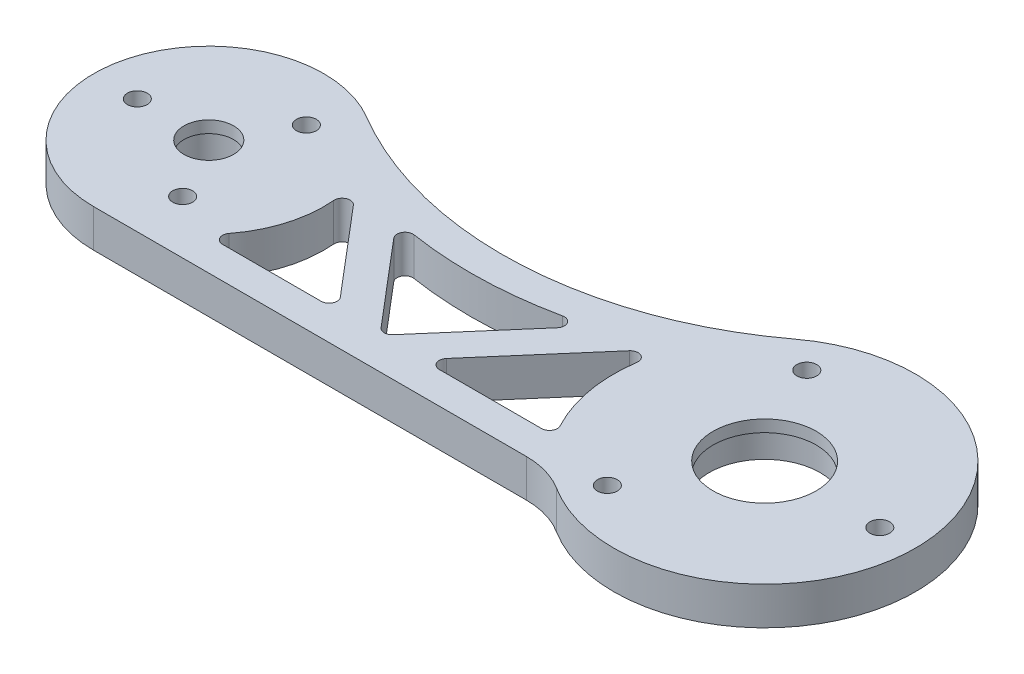
from build123d import *

# Parameters (mm, degrees)
BOSS_EXTRUDE1_DEPTH   = 4.7625
CUT_EXTRUDE1_DEPTH    = 5.7625
CUT_EXTRUDE2_DEPTH    = 5.7625
FILLET1_R             = 1
SKETCH4_R             = 4
BOSS_EXTRUDE3_DEPTH   = 4.7625
SKETCH5_R             = 3.125
CUT_EXTRUDE3_DEPTH    = 5.7625
SKETCH6_R             = 3.5
CUT_EXTRUDE4_DEPTH    = 3.2625
SKETCH7_R             = 6.5
CUT_EXTRUDE5_DEPTH    = 5.7625
SKETCH8_R             = 7
CUT_EXTRUDE6_DEPTH    = 3.2625
M3X0_5_TAPPED_HOLE1_D = 2.5
M3X0_5_TAPPED_HOLE2_D = 2.5


with BuildPart() as part:
    # Sketch1 → Boss-Extrude1 (new body)
    with BuildSketch(Plane(origin=(0, 0, 0), x_dir=(1, 0, 0), z_dir=(0, 1, 0))):
        with BuildLine():
            Line((-35, 14.5), (19.483879351, 14.5))
            ThreePointArc((19.483879351, 14.5), (22.269309423, 14.89576243), (24.834265782, 16.051724138))
            ThreePointArc((24.834265782, 16.051724138), (54, 0), (24.834265782, -16.051724138))
            ThreePointArc((24.834265782, -16.051724138), (22.269309423, -14.89576243), (19.483879351, -14.5))
            Line((19.483879351, -14.5), (-35, -14.5))
            ThreePointArc((-35, -14.5), (-49.5, 0), (-35, 14.5))
        make_face()
    extrude(amount=BOSS_EXTRUDE1_DEPTH)

    # Sketch2 → Cut-Extrude1 (cut, through all)
    with BuildSketch(Plane(origin=(0, 4.7625, 0), x_dir=(1, 0, 0), z_dir=(0, 1, 0))):
        with BuildLine():
            Line((-35, 14.5), (27.609823933, 17.503865221))
            ThreePointArc((27.609823933, 17.503865221), (25.539879113, 16.477442544), (23.609823933, 15.207362991))
            ThreePointArc((23.609823933, 15.207362991), (-1.577083946, 6.065910022), (-27.59576752, 12.467050228))
            ThreePointArc((-27.59576752, 12.467050228), (-31.160874338, 13.98252889), (-35, 14.5))
        make_face()
    extrude(amount=-CUT_EXTRUDE1_DEPTH, mode=Mode.SUBTRACT)

    # Sketch3 → Cut-Extrude2 (cut, through all)
    with BuildSketch(Plane(origin=(0, 4.7625, 0), x_dir=(1, 0, 0), z_dir=(0, 1, 0))):
        with BuildLine():
            Line((-25, -10.5), (-8.18305643, -10.5))
            Line((-8.18305643, -10.5), (-21.431362429, 5.11293208))
            ThreePointArc((-21.431362429, 5.11293208), (-20.86454524, -3.230931556), (-25, -10.5))
        make_face()
        with BuildLine():
            Line((-14.47546762, 3.097845852), (-2.937056907, -10.5))
            Line((-2.937056907, -10.5), (9.456330798, 3.851674059))
            ThreePointArc((9.456330798, 3.851674059), (-2.463897631, 2.02484882), (-14.47546762, 3.097845852))
        make_face()
        with BuildLine():
            Line((17.235698957, 6.740148995), (2.347968808, -10.5))
            Line((2.347968808, -10.5), (19.164912378, -10.5))
            ThreePointArc((19.164912378, -10.5), (16.117854624, -2.112956696), (17.235698957, 6.740148995))
        make_face()
    extrude(amount=-CUT_EXTRUDE2_DEPTH, mode=Mode.SUBTRACT)

    # Fillet1
    fillet1_edges = [part.edges().sort_by_distance(p)[0] for p in [
        (17.235698957, 2.38125, -6.740148995),
        (19.164912378, 2.38125, 10.5),
        (2.347968808, 2.38125, 10.5),
        (-21.431362429, 2.38125, -5.11293208),
        (-8.18305643, 2.38125, 10.5),
        (-25, 2.38125, 10.5),
        (-14.47546762, 2.38125, -3.097845852),
        (9.456330798, 2.38125, -3.851674059),
        (-2.937056907, 2.38125, 10.5),
    ]]
    fillet(fillet1_edges, radius=FILLET1_R)

    # Sketch4 → Boss-Extrude3 (add, through all)
    with BuildSketch(Plane(origin=(0, 4.7625, 0), x_dir=(1, 0, 0), z_dir=(0, 1, 0))):
        with Locations((-35, 0)):
            Circle(SKETCH4_R)
    extrude(amount=-BOSS_EXTRUDE3_DEPTH)

    # Sketch5 → Cut-Extrude3 (cut, through all)
    with BuildSketch(Plane(origin=(0, 4.7625, 0), x_dir=(1, 0, 0), z_dir=(0, 1, 0))):
        with Locations((-35, 0)):
            Circle(SKETCH5_R)
    extrude(amount=-CUT_EXTRUDE3_DEPTH, mode=Mode.SUBTRACT)

    # Sketch6 → Cut-Extrude4 (cut)
    with BuildSketch(Plane(origin=(0, 0, 0), x_dir=(1, 0, 0), z_dir=(0, 1, 0))):
        with Locations((-35, 0)):
            Circle(SKETCH6_R)
    extrude(amount=CUT_EXTRUDE4_DEPTH, mode=Mode.SUBTRACT)

    # Sketch7 → Cut-Extrude5 (cut, through all)
    with BuildSketch(Plane.XZ):
        with Locations((35, 0)):
            Circle(SKETCH7_R)
    extrude(amount=-CUT_EXTRUDE5_DEPTH, mode=Mode.SUBTRACT)

    # Sketch8 → Cut-Extrude6 (cut)
    with BuildSketch(Plane.XZ):
        with Locations((35, 0)):
            Circle(SKETCH8_R)
    extrude(amount=-CUT_EXTRUDE6_DEPTH, mode=Mode.SUBTRACT)

    # M3x0.5 Tapped Hole1 (through all)
    with Locations(Plane.XZ):
        with Locations((27.75, -12.557368355), (27.75, 12.557368355), (49.5, 0), (-44, 0), (-30.5, 7.794228634), (-30.5, -7.794228634)):
            Hole(M3X0_5_TAPPED_HOLE1_D / 2)

    # M3x0.5 Tapped Hole2 (through all)
    with Locations(Plane(origin=(0, 4.7625, 0), x_dir=(-1, 0, 0), z_dir=(0, 1, 0))):
        with Locations((30.5, 7.794228634), (44, 0), (30.5, -7.794228634)):
            Hole(M3X0_5_TAPPED_HOLE2_D / 2)


solid = part.part
